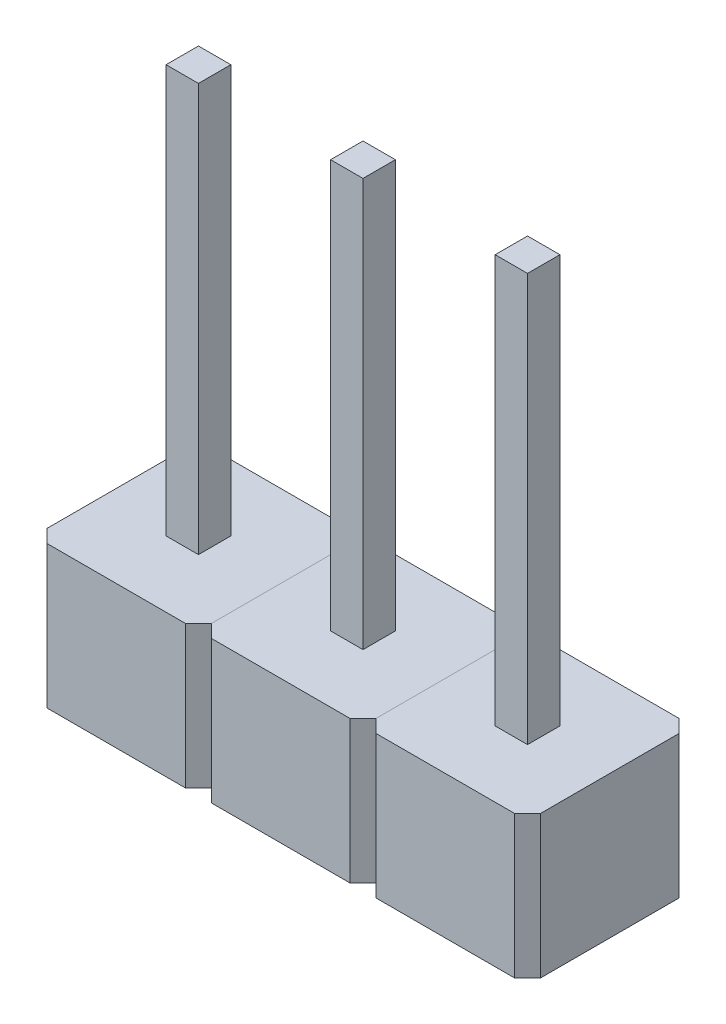
from build123d import *

# Parameters (mm, degrees)
CROQUIS1_W       = 0.5
CROQUIS1_H       = 0.5
EXTRUIR1_DEPTH   = 8.5
EXTRUIR1_2_DEPTH = 8.5
EXTRUIR1_3_DEPTH = 8.5
CROQUIS2_W       = 2.54
CROQUIS2_H       = 2.54
CROQUIS2_W_2     = 0.5
CROQUIS2_H_2     = 0.5
EXTRUIR2_DEPTH   = 2.2
CHAFL_N1_SIZE    = 0.2
MATRIZL1_COUNT   = 3
MATRIZL1_PITCH   = 2.54


with BuildPart() as part:
    # Croquis1 → Extruir1 (new body)
    with BuildSketch(Plane(origin=(0, 0, 0), x_dir=(1, 0, 0), z_dir=(0, 1, 0))):
        with Locations((2.79, 0.25)):
            Rectangle(CROQUIS1_W, CROQUIS1_H)
    extrude(amount=EXTRUIR1_DEPTH)


with BuildPart() as body_2:
    # Croquis1 → Extruir1 2 (new body)
    with BuildSketch(Plane(origin=(0, 0, 0), x_dir=(1, 0, 0), z_dir=(0, 1, 0))):
        with Locations((0.25, 0.25)):
            Rectangle(CROQUIS1_W, CROQUIS1_H)
    extrude(amount=EXTRUIR1_2_DEPTH)


with BuildPart() as body_3:
    # Croquis1 → Extruir1 3 (new body)
    with BuildSketch(Plane(origin=(0, 0, 0), x_dir=(1, 0, 0), z_dir=(0, 1, 0))):
        with Locations((5.33, 0.25)):
            Rectangle(CROQUIS1_W, CROQUIS1_H)
    extrude(amount=EXTRUIR1_3_DEPTH)


with BuildPart() as body_4:
    # Croquis2 → Extruir2 (new body)
    with BuildSketch(Plane.XZ):
        with Locations((0.25, -0.25)):
            Rectangle(CROQUIS2_W, CROQUIS2_H)
        with Locations((0.25, -0.25)):
            Rectangle(CROQUIS2_W_2, CROQUIS2_H_2, mode=Mode.SUBTRACT)
    extrude(amount=-EXTRUIR2_DEPTH)

    # Chaflán1
    chafl_n1_edges = [body_4.edges().sort_by_distance(p)[0] for p in [
        (-1.02, 1.1, 1.02),
        (1.52, 1.1, 1.02),
        (1.52, 1.1, -1.52),
        (-1.02, 1.1, -1.52),
    ]]
    chamfer(chafl_n1_edges, length=CHAFL_N1_SIZE)


with BuildPart() as matrizl1_1:
    # MatrizL1: pattern copy
    add(body_4.part.moved(Location(Vector(1, 0, 0) * (1 * MATRIZL1_PITCH))))


with BuildPart() as matrizl1_2:
    # MatrizL1: pattern copy
    add(body_4.part.moved(Location(Vector(1, 0, 0) * (2 * MATRIZL1_PITCH))))


solid = Compound([part.part, body_2.part, body_3.part, body_4.part, matrizl1_1.part, matrizl1_2.part])
